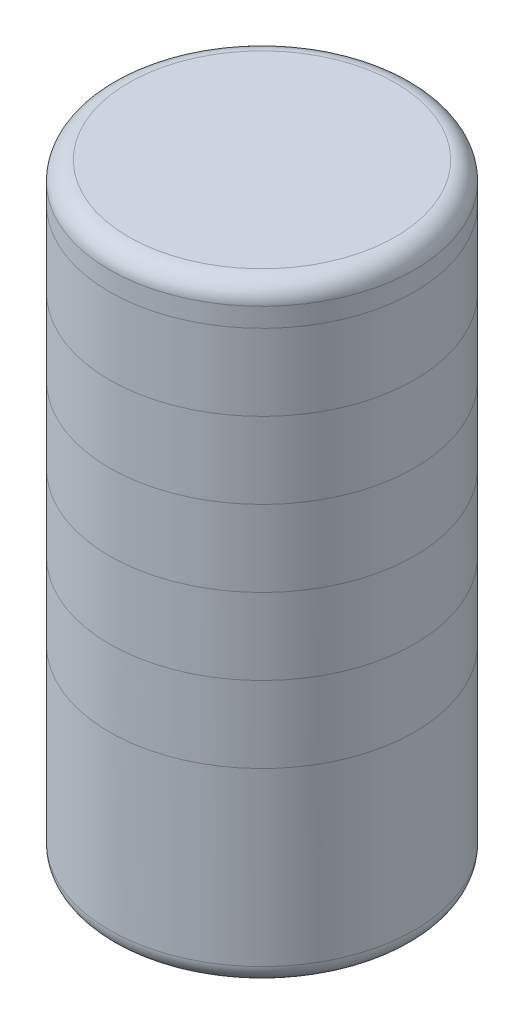
from build123d import *

# Parameters (mm, degrees)
SKETCH1_R           = 25.4
BOSS_EXTRUDE1_DEPTH = 101.6
FILLET1_R           = 3.175
FILLET2_R           = 3.175


with BuildPart() as part:
    # Sketch1 → Boss-Extrude1 (new body)
    with BuildSketch(Plane(origin=(0, 0, 0), x_dir=(1, 0, 0), z_dir=(0, 1, 0))):
        Circle(SKETCH1_R)
    extrude(amount=BOSS_EXTRUDE1_DEPTH)

    # Fillet1
    fillet1_edges = [part.edges().sort_by_distance(p)[0] for p in [
        (-25.4, 101.6, 0),
    ]]
    fillet(fillet1_edges, radius=FILLET1_R)

    # Fillet2
    fillet2_edges = [part.edges().sort_by_distance(p)[0] for p in [
        (-25.4, 0, 0),
    ]]
    fillet(fillet2_edges, radius=FILLET2_R)


solid = part.part
